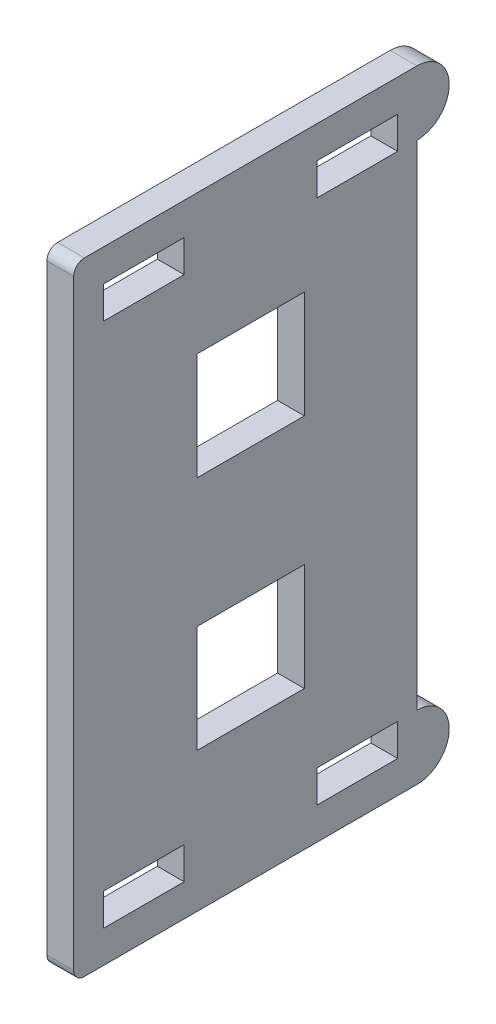
from build123d import *

# Parameters (mm, degrees)
SKETCH_2_W          = 35
SKETCH_2_H          = 58
EXTRUDE_1_DEPTH     = 2.5
SKETCH_4_W          = 7.5
SKETCH_4_H          = 3
CUT_EXTRUDE_1_DEPTH = 3.5
CUT_EXTRUDE_2_DEPTH = 3.5
SKETCH_7_W          = 10
SKETCH_7_H          = 10
CUT_EXTRUDE_3_DEPTH = 3.5
FILLET_1_R          = 1


with BuildPart() as part:
    # 草图2 → 凸台-拉伸1 (new body)
    with BuildSketch(Plane(origin=(0, 0, 0), x_dir=(0, 0, -1), z_dir=(1, 0, 0))):
        Rectangle(SKETCH_2_W, SKETCH_2_H)
    extrude(amount=EXTRUDE_1_DEPTH)

    # 草图4 → 切除-拉伸1 (cut, through all)
    with BuildSketch(Plane.ZY):
        with Locations((-8.95, 24.5)):
            Rectangle(SKETCH_4_W, SKETCH_4_H)
        with Locations((10.95, 24.5)):
            Rectangle(SKETCH_4_W, SKETCH_4_H)
        with Locations((-8.95, -24.5)):
            Rectangle(SKETCH_4_W, SKETCH_4_H)
        with Locations((10.95, -24.5)):
            Rectangle(SKETCH_4_W, SKETCH_4_H)
    extrude(amount=-CUT_EXTRUDE_1_DEPTH, mode=Mode.SUBTRACT)

    # 草图5 → 切除-拉伸2 (cut, through all)
    with BuildSketch(Plane.ZY):
        with BuildLine():
            Line((-17.5, 29), (-17.5, 26.000000007))
            ThreePointArc((-17.5, 26.000000007), (-16.621320341, 28.121320346), (-14.5, 29))
            Line((-14.5, 29), (-17.5, 29))
        make_face()
        with BuildLine():
            Line((-14.5, 0), (-14.5, 23))
            ThreePointArc((-14.5, 23), (-16.621320346, 23.878679659), (-17.5, 26.000000007))
            Line((-17.5, 26.000000007), (-17.5, 0))
            Line((-17.5, 0), (-14.5, 0))
        make_face()
        with BuildLine():
            Line((-14.5, -23), (-14.5, 0))
            Line((-14.5, 0), (-17.5, 0))
            Line((-17.5, 0), (-17.5, -26))
            ThreePointArc((-17.5, -26), (-16.621320344, -23.878679656), (-14.5, -23))
        make_face()
        with BuildLine():
            ThreePointArc((-14.5, -29), (-16.621320344, -28.121320344), (-17.5, -26))
            Line((-17.5, -26), (-17.5, -29))
            Line((-17.5, -29), (-14.5, -29))
        make_face()
    extrude(amount=-CUT_EXTRUDE_2_DEPTH, mode=Mode.SUBTRACT)

    # 草图7 → 切除-拉伸3 (cut, through all)
    with BuildSketch(Plane.ZY):
        with Locations((1, -11)):
            Rectangle(SKETCH_7_W, SKETCH_7_H)
        with Locations((1, 11)):
            Rectangle(SKETCH_7_W, SKETCH_7_H)
    extrude(amount=-CUT_EXTRUDE_3_DEPTH, mode=Mode.SUBTRACT)

    # 圆角1
    fillet_1_edges = [part.edges().sort_by_distance(p)[0] for p in [
        (1.25, -29, 17.5),
        (1.25, 29, 17.5),
    ]]
    fillet(fillet_1_edges, radius=FILLET_1_R)


solid = part.part
